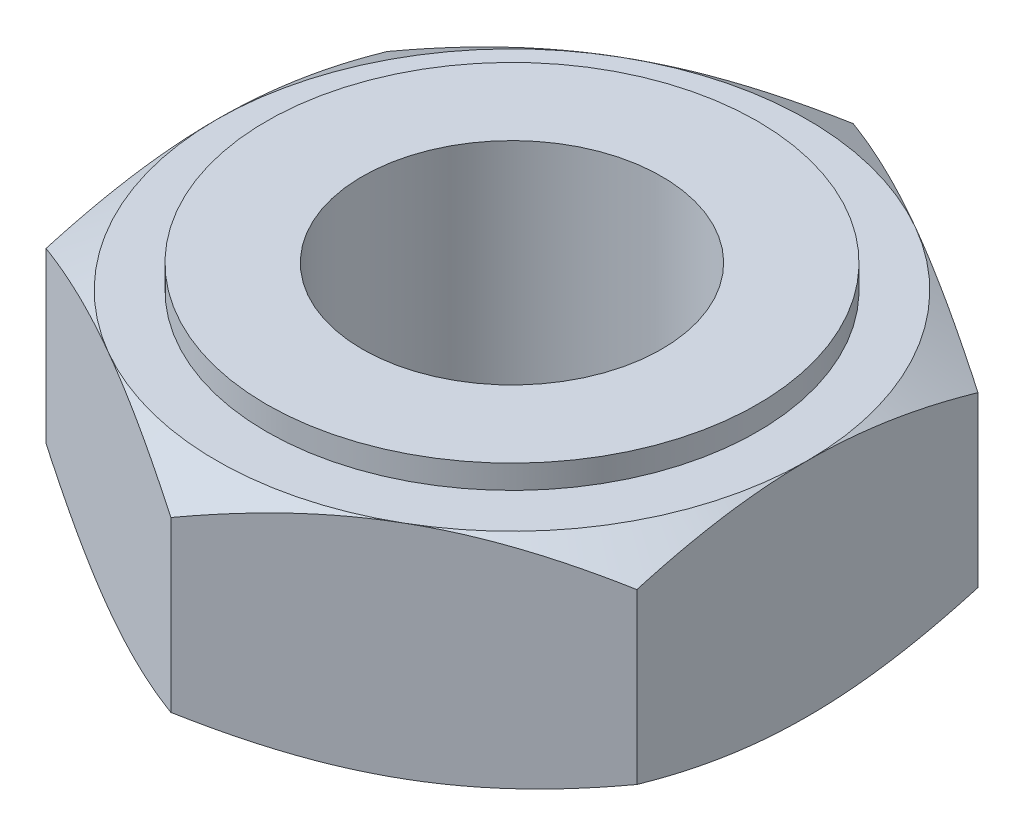
from build123d import *

# Parameters (mm, degrees)
SKETCH1_R               = 2.413
BOSS_EXTRUDE1_DEPTH     = 1.7859375
SKETCH6_R               = 3.956130657
SKETCH6_R_2             = 2.413
BOSS_EXTRUDE2_DEPTH     = 0.381
SKETCH5_OUTSIDE_W       = 46.08
SKETCH5_OUTSIDE_H       = 47.552
SKETCH5_OUTSIDE_R       = 4.7625
CUT_EXTRUDE2_DEPTH      = 9.104416837
CUT_EXTRUDE2_DRAFT      = -60
MIRROR1_COPY_1_SKETCH_W = 46.08
MIRROR1_COPY_1_SKETCH_H = 47.552
MIRROR1_COPY_1_SKETCH_R = 4.7625
MIRROR1_COPY_1_DEPTH    = 9.104416837
MIRROR1_COPY_1_DRAFT    = -60


with BuildPart() as part:
    # Sketch1 → Boss-Extrude1 (new, symmetric)
    with BuildSketch(Plane(origin=(0, 0, 0), x_dir=(1, 0, 0), z_dir=(0, 1, 0))):
        Polygon((-4.7625, 2.749630657), (-4.7625, -2.749630657), (0, -5.499261314), (4.7625, -2.749630657), (4.7625, 2.749630657), (0, 5.499261314), align=None)
        Circle(SKETCH1_R, mode=Mode.SUBTRACT)
    extrude(amount=BOSS_EXTRUDE1_DEPTH, both=True)

    # Sketch6 → Boss-Extrude2 (add)
    with BuildSketch(Plane(origin=(0, 1.7859375, 0), x_dir=(1, 0, 0), z_dir=(0, 1, 0))):
        Circle(SKETCH6_R)
        Circle(SKETCH6_R_2, mode=Mode.SUBTRACT)
    extrude(amount=BOSS_EXTRUDE2_DEPTH)


with BuildPart() as cut_extrude2_tool:
    # Sketch5 outside → Cut-Extrude2 (with draft: the straight prism first)
    with BuildSketch(Plane(origin=(0, 1.7859375, 0), x_dir=(1, 0, 0), z_dir=(0, 1, 0))):
        Rectangle(SKETCH5_OUTSIDE_W, SKETCH5_OUTSIDE_H)
        Circle(SKETCH5_OUTSIDE_R, mode=Mode.SUBTRACT)
    extrude(amount=-CUT_EXTRUDE2_DEPTH)
    # Cut-Extrude2: the draft: its side faces are tilted about the plane it starts from
    cut_extrude2_sides = [cut_extrude2_tool.faces().sort_by_distance(p)[0] for p in [
        (0, -2.766270918, 23.776),
        (23.04, -2.766270918, 0),
        (0, -2.766270918, -23.776),
        (-23.04, -2.766270918, 0),
        (-4.7625, -2.766270918, 0),
    ]]
    draft(cut_extrude2_sides, Plane(origin=(0, 1.7859375, 0), x_dir=(1, 0, 0), z_dir=(0, 1, 0)), CUT_EXTRUDE2_DRAFT)


with BuildPart() as part_1:
    add(part.part)

    # Cut-Extrude2: cut by cut_extrude2_tool
    add(cut_extrude2_tool.part, mode=Mode.SUBTRACT)


with BuildPart() as mirror1_copy_1_tool:
    # Mirror1 copy 1 sketch → Mirror1 copy 1 (with draft: the straight prism first)
    with BuildSketch(Plane.XZ.offset(1.7859375)):
        Rectangle(MIRROR1_COPY_1_SKETCH_W, MIRROR1_COPY_1_SKETCH_H)
        Circle(MIRROR1_COPY_1_SKETCH_R, mode=Mode.SUBTRACT)
    extrude(amount=-MIRROR1_COPY_1_DEPTH)
    # Mirror1 copy 1: the draft: its side faces are tilted about the plane it starts from
    mirror1_copy_1_sides = [mirror1_copy_1_tool.faces().sort_by_distance(p)[0] for p in [
        (0, 2.766270918, 23.776),
        (23.04, 2.766270918, 0),
        (0, 2.766270918, -23.776),
        (-23.04, 2.766270918, 0),
        (-4.7625, 2.766270918, 0),
    ]]
    draft(mirror1_copy_1_sides, Plane.XZ.offset(1.7859375), MIRROR1_COPY_1_DRAFT)


with BuildPart() as part_2:
    add(part_1.part)

    # Mirror1 copy 1: cut by mirror1_copy_1_tool
    add(mirror1_copy_1_tool.part, mode=Mode.SUBTRACT)


solid = part_2.part
